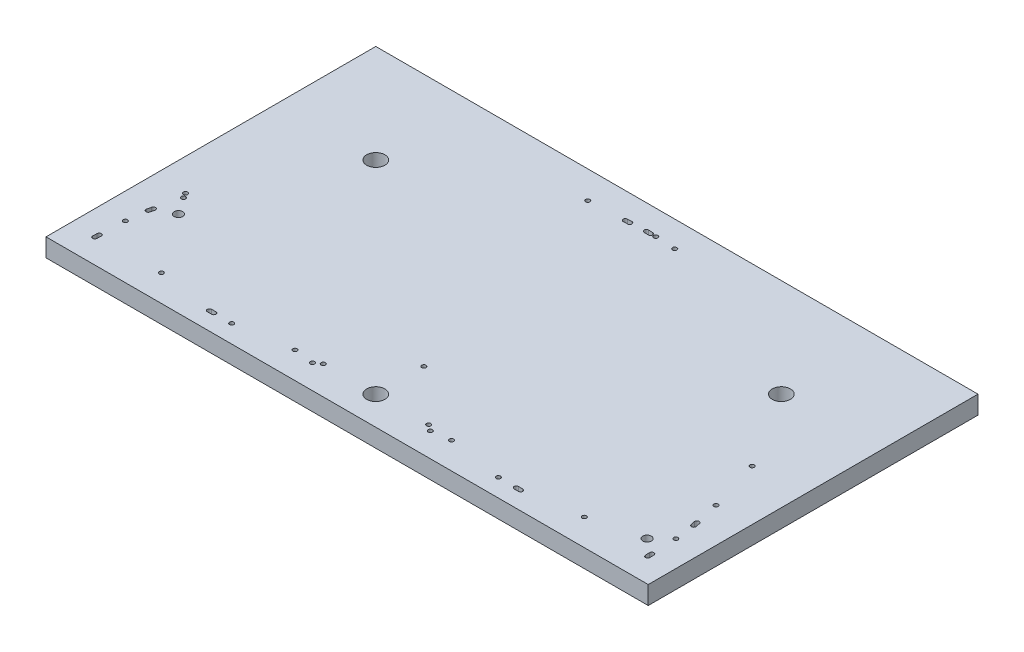
from build123d import *

# Parameters (mm, degrees)
SKETCH1_W           = 420
SKETCH1_H           = 230
BOSS_EXTRUDE1_DEPTH = 12.7
SKETCH7_R           = 6.35
SKETCH7_R_2         = 1.5
SKETCH7_R_3         = 3
CUT_EXTRUDE1_DEPTH  = 12.7


with BuildPart() as part:
    # Sketch1 → Boss-Extrude1 (new body)
    with BuildSketch(Plane(origin=(0, 0, 0), x_dir=(1, 0, 0), z_dir=(0, 1, 0))):
        with Locations((210, 115)):
            Rectangle(SKETCH1_W, SKETCH1_H)
    extrude(amount=BOSS_EXTRUDE1_DEPTH)

    # Sketch7 → Cut-Extrude1 (cut)
    with BuildSketch(Plane(origin=(196.460458651, 12.7, -62.603037437), x_dir=(0.090258341, 0, 0.995918386), z_dir=(0, 1, 0))):
        with BuildLine():
            Line((62.136725244, 113.896063379), (62.407500266, 116.883818538))
            ThreePointArc((62.407500266, 116.883818538), (61.049010198, 118.513083628), (59.419745108, 117.15459356))
            Line((59.419745108, 117.15459356), (59.148970086, 114.166838401))
            ThreePointArc((59.148970086, 114.166838401), (60.507460154, 112.537573311), (62.136725244, 113.896063379))
        make_face()
        with BuildLine():
            Line((40.104460202, -95.971941083), (39.83368518, -98.959696242))
            ThreePointArc((39.83368518, -98.959696242), (41.192175248, -100.588961332), (42.821440338, -99.230471264))
            Line((42.821440338, -99.230471264), (43.09221536, -96.242716105))
            ThreePointArc((43.09221536, -96.242716105), (41.733725292, -94.613451015), (40.104460202, -95.971941083))
        make_face()
        with BuildLine():
            Line((26.652261004, 200.049176763), (29.626595588, 200.44075534))
            ThreePointArc((29.626595588, 200.44075534), (30.917973591, 202.12371192), (29.235017011, 203.415089924))
            Line((29.235017011, 203.415089924), (26.260682427, 203.023511347))
            ThreePointArc((26.260682427, 203.023511347), (24.969304423, 201.340554767), (26.652261004, 200.049176763))
        make_face()
        with BuildLine():
            Line((-149.807347164, 26.185559118), (-150.185944072, 23.209544269))
            ThreePointArc((-150.185944072, 23.209544269), (-148.887235101, 21.532238391), (-147.209929223, 22.830947362))
            Line((-147.209929223, 22.830947362), (-146.831332315, 25.806962211))
            ThreePointArc((-146.831332315, 25.806962211), (-148.130041286, 27.484268089), (-149.807347164, 26.185559118))
        make_face()
        with BuildLine():
            Line((26.260682427, -183.745513941), (29.235017011, -184.137092518))
            ThreePointArc((29.235017011, -184.137092518), (30.917973591, -182.845714514), (29.626595588, -181.162757934))
            Line((29.626595588, -181.162757934), (26.652261004, -180.771179357))
            ThreePointArc((26.652261004, -180.771179357), (24.969304423, -182.062557361), (26.260682427, -183.745513941))
        make_face()
        with BuildLine():
            Line((61.159179013, 200.00504307), (64.155240602, 199.851371503))
            ThreePointArc((64.155240602, 199.851371503), (65.73010718, 201.272566515), (64.308912169, 202.847433093))
            Line((64.308912169, 202.847433093), (61.312850579, 203.001104659))
            ThreePointArc((61.312850579, 203.001104659), (59.737984001, 201.579909648), (61.159179013, 200.00504307))
        make_face()
        with BuildLine():
            Line((-150.501934623, 12.161279271), (-150.655606189, 9.165217681))
            ThreePointArc((-150.655606189, 9.165217681), (-149.234411177, 7.590351103), (-147.659544599, 9.011546115))
            Line((-147.659544599, 9.011546115), (-147.505873033, 12.007607705))
            ThreePointArc((-147.505873033, 12.007607705), (-148.927068045, 13.582474283), (-150.501934623, 12.161279271))
        make_face()
        with BuildLine():
            Line((-8.222616285, -177.468207688), (-5.367140889, -178.388131742))
            ThreePointArc((-5.367140889, -178.388131742), (-3.479441164, -177.420356071), (-4.447216835, -175.532656346))
            Line((-4.447216835, -175.532656346), (-7.302692231, -174.612732292))
            ThreePointArc((-7.302692231, -174.612732292), (-9.190391955, -175.580507963), (-8.222616285, -177.468207688))
        make_face()
        with Locations(Location((43.651204827, 9.638998703, 0), (0, 0, 354.82153059))):  # turned: the seam where the file's is
            Circle(SKETCH7_R)
        with Locations(Location((-109.957381, -118.440673222, 0), (0, 0, 354.82153059))):  # turned: the seam where the file's is
            Circle(SKETCH7_R)
        with Locations(Location((43.099653048, -31.508080441, 0), (0, 0, 354.82153059))):  # turned: the seam where the file's is
            Circle(SKETCH7_R_2)
        with Locations(Location((9.106186641, -179.974138285, 0), (0, 0, 354.82153059))):  # turned: the seam where the file's is
            Circle(SKETCH7_R_2)
        with Locations(Location((42.72656704, -83.658348767, 0), (0, 0, 354.82153059))):  # turned: the seam where the file's is
            Circle(SKETCH7_R_2)
        with Locations(Location((59.514618406, 101.582471063, 0), (0, 0, 354.82153059))):  # turned: the seam where the file's is
            Circle(SKETCH7_R_2)
        with Locations(Location((9.106186641, 199.252135691, 0), (0, 0, 354.82153059))):  # turned: the seam where the file's is
            Circle(SKETCH7_R_2)
        with Locations(Location((-146.11085778, 43.356347284, 0), (0, 0, 354.82153059))):  # turned: the seam where the file's is
            Circle(SKETCH7_R_2)
        with Locations(Location((46.986103661, 46.369904384, 0), (0, 0, 354.82153059))):  # turned: the seam where the file's is
            Circle(SKETCH7_R_2)
        with Locations(Location((31.778994905, -137.978961535, 0), (0, 0, 354.82153059))):  # turned: the seam where the file's is
            Circle(SKETCH7_R_2)
        with Locations(Location((40.195997242, -45.105025216, 0), (0, 0, 354.82153059))):  # turned: the seam where the file's is
            Circle(SKETCH7_R_2)
        with Locations(Location((50.040444185, 63.519459099, 0), (0, 0, 354.82153059))):  # turned: the seam where the file's is
            Circle(SKETCH7_R_2)
        with Locations(Location((58.404584222, 155.810108196, 0), (0, 0, 354.82153059))):  # turned: the seam where the file's is
            Circle(SKETCH7_R_2)
        with Locations(Location((10.28793889, 12.662653116, 0), (0, 0, 354.82153059))):  # turned: the seam where the file's is
            Circle(SKETCH7_R_2)
        with Locations(Location((40.359061234, -26.859260892, 0), (0, 0, 354.82153059))):  # turned: the seam where the file's is
            Circle(SKETCH7_R_2)
        with Locations(Location((50.526634497, 50.371125536, 0), (0, 0, 354.82153059))):  # turned: the seam where the file's is
            Circle(SKETCH7_R_2)
        with Locations(Location((-84.428467098, 163.24758453, 0), (0, 0, 354.82153059))):  # turned: the seam where the file's is
            Circle(SKETCH7_R)
        with Locations(Location((-27.999784998, 191.535633244, 0), (0, 0, 354.82153059))):  # turned: the seam where the file's is
            Circle(SKETCH7_R_2)
        with Locations(Location((-150.176265572, -15.878871876, 0), (0, 0, 354.82153059))):  # turned: the seam where the file's is
            Circle(SKETCH7_R_2)
        with Locations(Location((-27.999784998, -172.257635837, 0), (0, 0, 354.82153059))):  # turned: the seam where the file's is
            Circle(SKETCH7_R_2)
        with Locations(Location((-12.157521123, -163.593175294, 0), (0, 0, 354.82153059))):  # turned: the seam where the file's is
            Circle(SKETCH7_R_3)
        with Locations(Location((52.722508699, 191.41279067, 0), (0, 0, 354.82153059))):  # turned: the seam where the file's is
            Circle(SKETCH7_R_3)
        with Locations(Location((-24.419594065, -170.674246341, 0), (0, 0, 354.82153059))):  # turned: the seam where the file's is
            Circle(SKETCH7_R_2)
        with Locations(Location((-148.050944539, 29.558484854, 0), (0, 0, 354.82153059))):  # turned: the seam where the file's is
            Circle(SKETCH7_R_2)
        with Locations(Location((43.757660715, 202.373242332, 0), (0, 0, 354.82153059))):  # turned: the seam where the file's is
            Circle(SKETCH7_R_2)
    extrude(amount=-CUT_EXTRUDE1_DEPTH, mode=Mode.SUBTRACT)


solid = part.part
